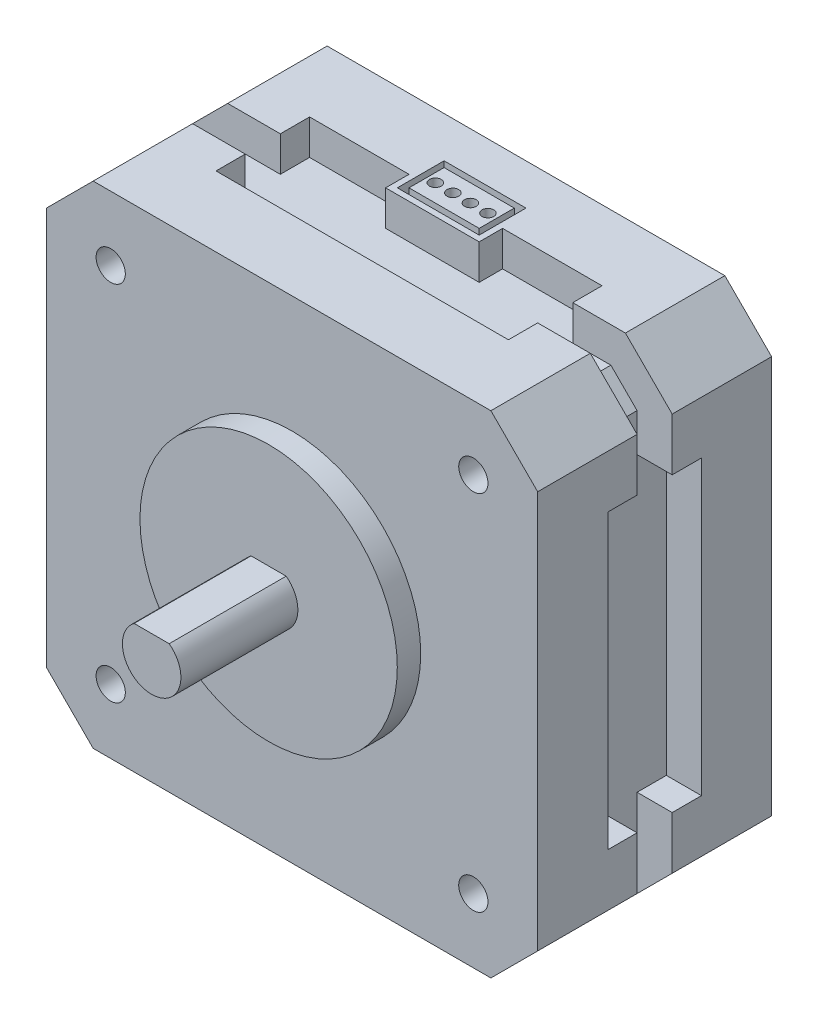
from build123d import *

# Parameters (mm, degrees)
SKETCH1_W                   = 42
SKETCH1_H                   = 42
BOSS_EXTRUDE1_DEPTH         = 10
CHAMFER1_SIZE               = 4
CUT_EXTRUDE1_DEPTH          = 1.5
SKETCH8_W                   = 25
SKETCH8_H                   = 3
SKETCH8_W_2                 = 3
SKETCH8_H_2                 = 25
CUT_EXTRUDE2_DEPTH          = 4
BOSS_EXTRUDE2_START         = 18
SKETCH9_W                   = 8
SKETCH9_H                   = 2
BOSS_EXTRUDE2_DEPTH         = 3
SKETCH10_W                  = 7
SKETCH10_H                  = 4
SKETCH10_W_2                = 6
SKETCH10_H_2                = 3
SKETCH10_R                  = 0.5
CUT_EXTRUDE3_DEPTH          = 3
SKETCH11_R                  = 11
BOSS_EXTRUDE3_DEPTH         = 2
BOSS_EXTRUDE4_DEPTH         = 20
TAP_DRILL_FOR_M3X0_5_TAP2_D = 2.5
SKETCH15_R                  = 3
SKETCH15_R_2                = 6
SKETCH15_R_3                = 4
CUT_EXTRUDE4_DEPTH          = 3
SKETCH16_R                  = 2.75
BOSS_EXTRUDE5_DEPTH         = 3
BOSS_EXTRUDE5_2_DEPTH       = 3
BOSS_EXTRUDE5_3_DEPTH       = 3
BOSS_EXTRUDE5_4_DEPTH       = 3
FILLET1_R                   = 2
FILLET2_R                   = 2
FILLET3_R                   = 2
FILLET4_R                   = 2
CUT_EXTRUDE5_DEPTH          = 2
FILLET5_R                   = 0.5
CUT_EXTRUDE6_DEPTH          = 10


with BuildPart() as part:
    # Sketch1 → Boss-Extrude1 (new body, symmetric)
    with BuildSketch(Plane.XY):
        Rectangle(SKETCH1_W, SKETCH1_H)
    extrude(amount=BOSS_EXTRUDE1_DEPTH, both=True)

    # Chamfer1
    chamfer1_edges = [part.edges().sort_by_distance(p)[0] for p in [
        (21, 21, 0),
        (21, -21, 0),
        (-21, -21, 0),
        (-21, 21, 0),
    ]]
    chamfer(chamfer1_edges, length=CHAMFER1_SIZE)

    # Sketch7 → Cut-Extrude1 (cut, symmetric)
    with BuildSketch(Plane.XY):
        Polygon((-21, 17), (-21, -17), (-17, -21), (17, -21), (21, -17), (21, 17), (17, 21), (-17, 21), align=None)
        Polygon((-18, 15.757359313), (-18, -15.757359313), (-15.757359313, -18), (15.757359313, -18), (18, -15.757359313), (18, 15.757359313), (15.757359313, 18), (-15.757359313, 18), align=None, mode=Mode.SUBTRACT)
    extrude(amount=CUT_EXTRUDE1_DEPTH, both=True, mode=Mode.SUBTRACT)

    # Sketch8 → Cut-Extrude2 (cut, symmetric)
    with BuildSketch(Plane.XY):
        with Locations((0, 19.5)):
            Rectangle(SKETCH8_W, SKETCH8_H)
        with Locations((-19.5, 0)):
            Rectangle(SKETCH8_W_2, SKETCH8_H_2)
        with Locations((0, -19.5)):
            Rectangle(SKETCH8_W, SKETCH8_H)
        with Locations((19.5, 0)):
            Rectangle(SKETCH8_W_2, SKETCH8_H_2)
    extrude(amount=CUT_EXTRUDE2_DEPTH, both=True, mode=Mode.SUBTRACT)

    # Sketch9 → Boss-Extrude2 (add)
    with BuildSketch(Plane(origin=(0, 0, 0), x_dir=(1, 0, 0), z_dir=(0, 1, 0)).offset(BOSS_EXTRUDE2_START)):
        with Locations((0, 3)):
            Rectangle(SKETCH9_W, SKETCH9_H)
    extrude(amount=BOSS_EXTRUDE2_DEPTH)

    # Sketch10 → Cut-Extrude3 (cut)
    with BuildSketch(Plane(origin=(0, 21, 0), x_dir=(1, 0, 0), z_dir=(0, 1, 0))):
        with Locations((0, 4.5)):
            Rectangle(SKETCH10_W, SKETCH10_H)
        with Locations((0, 4.5)):
            Rectangle(SKETCH10_W_2, SKETCH10_H_2, mode=Mode.SUBTRACT)
        with Locations((-0.75, 4.5)):
            Circle(SKETCH10_R)
        with Locations((0.75, 4.5)):
            Circle(SKETCH10_R)
        with Locations((2.25, 4.5)):
            Circle(SKETCH10_R)
        with Locations((-2.25, 4.5)):
            Circle(SKETCH10_R)
    extrude(amount=-CUT_EXTRUDE3_DEPTH, mode=Mode.SUBTRACT)

    # Sketch11 → Boss-Extrude3 (add)
    with BuildSketch(Plane.XY.offset(10)):
        Circle(SKETCH11_R)
    extrude(amount=BOSS_EXTRUDE3_DEPTH)

    # Sketch12 → Boss-Extrude4 (add)
    with BuildSketch(Plane.XY.offset(12)):
        with BuildLine():
            Line((1.5, 2), (-1.5, 2))
            ThreePointArc((-1.5, 2), (0, -2.5), (1.5, 2))
        make_face()
    extrude(amount=BOSS_EXTRUDE4_DEPTH)

    # Tap Drill for M3x0.5 Tap2 (through all)
    with Locations(Plane.XY.offset(10)):
        with Locations((-15.5, 15.5), (15.5, 15.5), (15.5, -15.5), (-15.5, -15.5)):
            Hole(TAP_DRILL_FOR_M3X0_5_TAP2_D / 2)

    # Sketch15 → Cut-Extrude4 (cut)
    with BuildSketch(Plane(origin=(0, 0, -10), x_dir=(-1, 0, 0), z_dir=(0, 0, -1))):
        with Locations((-15.5, 15.5)):
            Circle(SKETCH15_R)
        with Locations((15.5, 15.5)):
            Circle(SKETCH15_R)
        with Locations((15.5, -15.5)):
            Circle(SKETCH15_R)
        with Locations((-15.5, -15.5)):
            Circle(SKETCH15_R)
        Circle(SKETCH15_R_2)
        Circle(SKETCH15_R_3, mode=Mode.SUBTRACT)
    extrude(amount=-CUT_EXTRUDE4_DEPTH, mode=Mode.SUBTRACT)

    # Fillet5
    fillet5_edges = [part.edges().sort_by_distance(p)[0] for p in [
        (6, 0, -10),
        (4, 0, -10),
    ]]
    fillet(fillet5_edges, radius=FILLET5_R)

    # Sketch18 → Cut-Extrude6 (cut)
    with BuildSketch(Plane.XY.offset(32)):
        with BuildLine():
            Line((1.5, 2), (-1.5, 2))
            ThreePointArc((-1.5, 2), (0, -2.5), (1.5, 2))
        make_face()
    extrude(amount=-CUT_EXTRUDE6_DEPTH, mode=Mode.SUBTRACT)


with BuildPart() as body_2:
    # Sketch16 → Boss-Extrude5 (new body)
    with BuildSketch(Plane(origin=(0, 0, -7), x_dir=(-1, 0, 0), z_dir=(0, 0, -1))):
        with Locations((-15.5, 15.5)):
            Circle(SKETCH16_R)
    extrude(amount=BOSS_EXTRUDE5_DEPTH)

    # Fillet1
    fillet1_edges = [body_2.edges().sort_by_distance(p)[0] for p in [
        (18.25, 15.5, -10),
    ]]
    fillet(fillet1_edges, radius=FILLET1_R)


with BuildPart() as body_3:
    # Sketch16 → Boss-Extrude5 2 (new body)
    with BuildSketch(Plane(origin=(0, 0, -7), x_dir=(-1, 0, 0), z_dir=(0, 0, -1))):
        with Locations((15.5, 15.5)):
            Circle(SKETCH16_R)
    extrude(amount=BOSS_EXTRUDE5_2_DEPTH)

    # Fillet2
    fillet2_edges = [body_3.edges().sort_by_distance(p)[0] for p in [
        (-12.75, 15.5, -10),
    ]]
    fillet(fillet2_edges, radius=FILLET2_R)


with BuildPart() as body_4:
    # Sketch16 → Boss-Extrude5 3 (new body)
    with BuildSketch(Plane(origin=(0, 0, -7), x_dir=(-1, 0, 0), z_dir=(0, 0, -1))):
        with Locations((15.5, -15.5)):
            Circle(SKETCH16_R)
    extrude(amount=BOSS_EXTRUDE5_3_DEPTH)

    # Fillet3
    fillet3_edges = [body_4.edges().sort_by_distance(p)[0] for p in [
        (-12.75, -15.5, -10),
    ]]
    fillet(fillet3_edges, radius=FILLET3_R)


with BuildPart() as body_5:
    # Sketch16 → Boss-Extrude5 4 (new body)
    with BuildSketch(Plane(origin=(0, 0, -7), x_dir=(-1, 0, 0), z_dir=(0, 0, -1))):
        with Locations((-15.5, -15.5)):
            Circle(SKETCH16_R)
    extrude(amount=BOSS_EXTRUDE5_4_DEPTH)

    # Fillet4
    fillet4_edges = [body_5.edges().sort_by_distance(p)[0] for p in [
        (18.25, -15.5, -10),
    ]]
    fillet(fillet4_edges, radius=FILLET4_R)


with BuildPart() as cut_extrude5_tool:
    # Sketch17 → Cut-Extrude5 (new body)
    with BuildSketch(Plane(origin=(0, 0, -10), x_dir=(-1, 0, 0), z_dir=(0, 0, -1))):
        with BuildLine():
            Line((-15.75, 14.25), (-15.75, 13.250495577))
            ThreePointArc((-15.75, 13.250495577), (-15.5, 13.236563555), (-15.25, 13.250495577))
            Line((-15.25, 13.250495577), (-15.25, 14.25))
            ThreePointArc((-15.25, 14.25), (-14.957106781, 14.957106781), (-14.25, 15.25))
            Line((-14.25, 15.25), (-13.262470629, 15.25))
            ThreePointArc((-13.262470629, 15.25), (-13.250040621, 15.50008372), (-13.265475165, 15.75))
            Line((-13.265475165, 15.75), (-14.25, 15.75))
            ThreePointArc((-14.25, 15.75), (-14.957106781, 16.042893219), (-15.25, 16.75))
            Line((-15.25, 16.75), (-15.25, 17.722631532))
            ThreePointArc((-15.25, 17.722631532), (-15.5, 17.736563555), (-15.75, 17.722631532))
            Line((-15.75, 17.722631532), (-15.75, 16.75))
            ThreePointArc((-15.75, 16.75), (-16.042893219, 16.042893219), (-16.75, 15.75))
            Line((-16.75, 15.75), (-17.734524835, 15.75))
            ThreePointArc((-17.734524835, 15.75), (-17.749959379, 15.50008372), (-17.737529371, 15.25))
            Line((-17.737529371, 15.25), (-16.75, 15.25))
            ThreePointArc((-16.75, 15.25), (-16.042893219, 14.957106781), (-15.75, 14.25))
        make_face()
        with BuildLine():
            Line((-14.25, -15.25), (-13.262470629, -15.25))
            ThreePointArc((-13.262470629, -15.25), (-13.250040621, -15.50008372), (-13.265475165, -15.75))
            Line((-13.265475165, -15.75), (-14.25, -15.75))
            ThreePointArc((-14.25, -15.75), (-14.957106781, -16.042893219), (-15.25, -16.75))
            Line((-15.25, -16.75), (-15.25, -17.722631532))
            ThreePointArc((-15.25, -17.722631532), (-15.5, -17.736563555), (-15.75, -17.722631532))
            Line((-15.75, -17.722631532), (-15.75, -16.75))
            ThreePointArc((-15.75, -16.75), (-16.042893219, -16.042893219), (-16.75, -15.75))
            Line((-16.75, -15.75), (-17.734524835, -15.75))
            ThreePointArc((-17.734524835, -15.75), (-17.749959379, -15.50008372), (-17.737529371, -15.25))
            Line((-17.737529371, -15.25), (-16.75, -15.25))
            ThreePointArc((-16.75, -15.25), (-16.042893219, -14.957106781), (-15.75, -14.25))
            Line((-15.75, -14.25), (-15.75, -13.250495577))
            ThreePointArc((-15.75, -13.250495577), (-15.5, -13.236563555), (-15.25, -13.250495577))
            Line((-15.25, -13.250495577), (-15.25, -14.25))
            ThreePointArc((-15.25, -14.25), (-14.957106781, -14.957106781), (-14.25, -15.25))
        make_face()
        with BuildLine():
            Line((15.75, -14.25), (15.75, -13.250495577))
            ThreePointArc((15.75, -13.250495577), (15.5, -13.236563555), (15.25, -13.250495577))
            Line((15.25, -13.250495577), (15.25, -14.25))
            ThreePointArc((15.25, -14.25), (14.957106781, -14.957106781), (14.25, -15.25))
            Line((14.25, -15.25), (13.262470629, -15.25))
            ThreePointArc((13.262470629, -15.25), (13.250040621, -15.50008372), (13.265475165, -15.75))
            Line((13.265475165, -15.75), (14.25, -15.75))
            ThreePointArc((14.25, -15.75), (14.957106781, -16.042893219), (15.25, -16.75))
            Line((15.25, -16.75), (15.25, -17.722631532))
            ThreePointArc((15.25, -17.722631532), (15.5, -17.736563555), (15.75, -17.722631532))
            Line((15.75, -17.722631532), (15.75, -16.75))
            ThreePointArc((15.75, -16.75), (16.042893219, -16.042893219), (16.75, -15.75))
            Line((16.75, -15.75), (17.734524835, -15.75))
            ThreePointArc((17.734524835, -15.75), (17.749959379, -15.50008372), (17.737529371, -15.25))
            Line((17.737529371, -15.25), (16.75, -15.25))
            ThreePointArc((16.75, -15.25), (16.042893219, -14.957106781), (15.75, -14.25))
        make_face()
        with BuildLine():
            Line((14.25, 15.25), (13.262470629, 15.25))
            ThreePointArc((13.262470629, 15.25), (13.250040621, 15.50008372), (13.265475165, 15.75))
            Line((13.265475165, 15.75), (14.25, 15.75))
            ThreePointArc((14.25, 15.75), (14.957106781, 16.042893219), (15.25, 16.75))
            Line((15.25, 16.75), (15.25, 17.722631532))
            ThreePointArc((15.25, 17.722631532), (15.5, 17.736563555), (15.75, 17.722631532))
            Line((15.75, 17.722631532), (15.75, 16.75))
            ThreePointArc((15.75, 16.75), (16.042893219, 16.042893219), (16.75, 15.75))
            Line((16.75, 15.75), (17.734524835, 15.75))
            ThreePointArc((17.734524835, 15.75), (17.749959379, 15.50008372), (17.737529371, 15.25))
            Line((17.737529371, 15.25), (16.75, 15.25))
            ThreePointArc((16.75, 15.25), (16.042893219, 14.957106781), (15.75, 14.25))
            Line((15.75, 14.25), (15.75, 13.250495577))
            ThreePointArc((15.75, 13.250495577), (15.5, 13.236563555), (15.25, 13.250495577))
            Line((15.25, 13.250495577), (15.25, 14.25))
            ThreePointArc((15.25, 14.25), (14.957106781, 14.957106781), (14.25, 15.25))
        make_face()
    extrude(amount=-CUT_EXTRUDE5_DEPTH)


with BuildPart() as body_2_1:
    add(body_2.part)

    # Cut-Extrude5: cut by cut_extrude5_tool
    add(cut_extrude5_tool.part, mode=Mode.SUBTRACT)


with BuildPart() as body_3_1:
    add(body_3.part)

    # Cut-Extrude5: cut by cut_extrude5_tool
    add(cut_extrude5_tool.part, mode=Mode.SUBTRACT)


with BuildPart() as body_4_1:
    add(body_4.part)

    # Cut-Extrude5: cut by cut_extrude5_tool
    add(cut_extrude5_tool.part, mode=Mode.SUBTRACT)


with BuildPart() as body_5_1:
    add(body_5.part)

    # Cut-Extrude5: cut by cut_extrude5_tool
    add(cut_extrude5_tool.part, mode=Mode.SUBTRACT)


solid = Compound([part.part, body_2_1.part, body_3_1.part, body_4_1.part, body_5_1.part])
